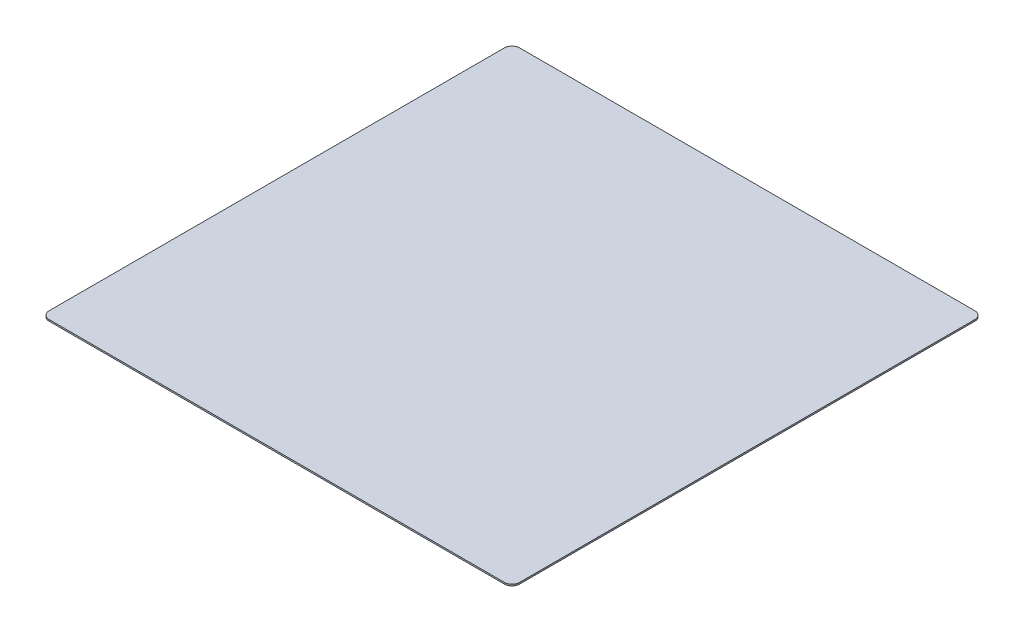
from build123d import *

# Parameters (mm, degrees)
EXTRUDE_1_DEPTH = 1


with BuildPart() as part:
    # 草图1 → 凸台-拉伸1 (new body)
    with BuildSketch(Plane(origin=(0, 0, 0), x_dir=(1, 0, 0), z_dir=(0, 1, 0))):
        with BuildLine():
            Line((-150, 155), (150, 155))
            ThreePointArc((150, 155), (153.535533906, 153.535533906), (155, 150))
            Line((155, 150), (155, -150))
            ThreePointArc((155, -150), (153.535533906, -153.535533906), (150, -155))
            Line((150, -155), (-150, -155))
            ThreePointArc((-150, -155), (-153.535533906, -153.535533906), (-155, -150))
            Line((-155, -150), (-155, 150))
            ThreePointArc((-155, 150), (-153.535533906, 153.535533906), (-150, 155))
        make_face()
    extrude(amount=EXTRUDE_1_DEPTH)


solid = part.part
